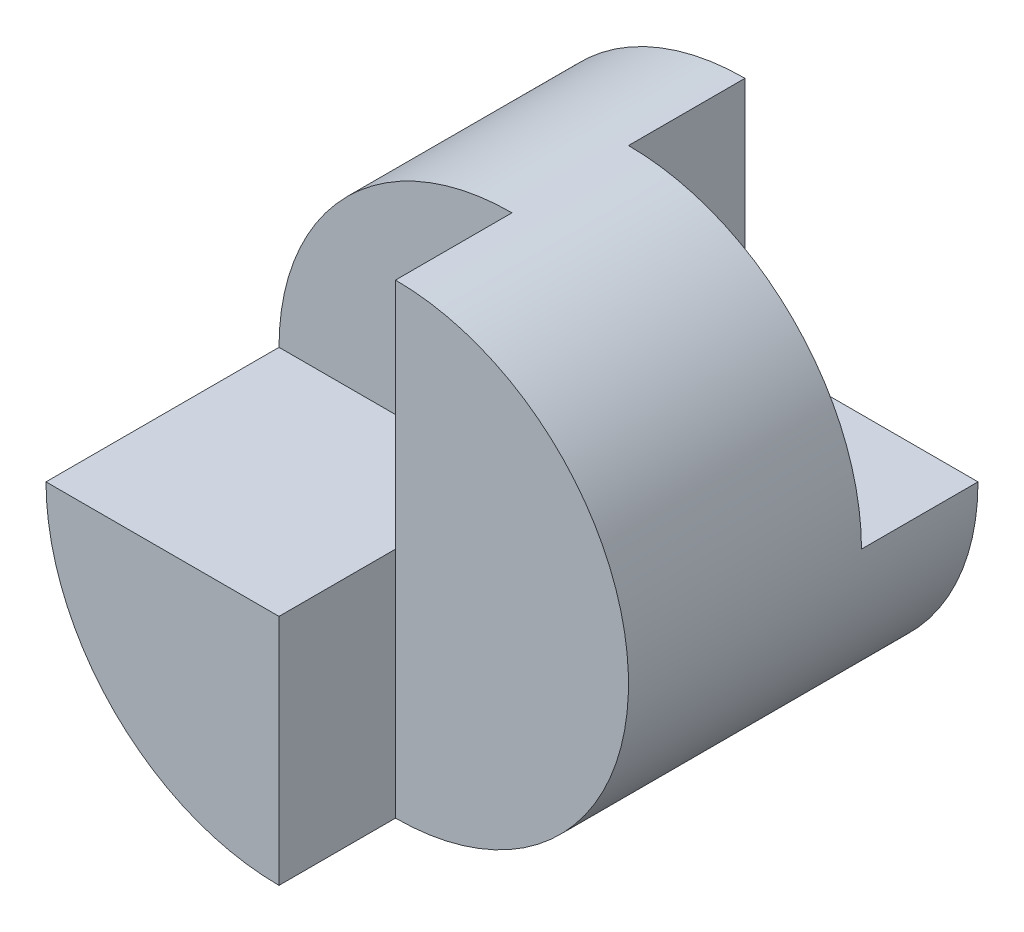
from build123d import *

# Parameters (mm, degrees)
SKETCH1_W           = 40
SKETCH1_H           = 40
BOSS_EXTRUDE1_DEPTH = 40
CUT_EXTRUDE1_DEPTH  = 40
SKETCH3_W           = 20
SKETCH3_H           = 10
CUT_EXTRUDE2_DEPTH  = 40
CUT_EXTRUDE3_DEPTH  = 20
CUT_EXTRUDE4_DEPTH  = 10


with BuildPart() as part:
    # Sketch1 → Boss-Extrude1 (new body)
    with BuildSketch(Plane.XY):
        with Locations((20, 20)):
            Rectangle(SKETCH1_W, SKETCH1_H)
    extrude(amount=BOSS_EXTRUDE1_DEPTH)

    # Sketch2 → Cut-Extrude1 (cut)
    with BuildSketch(Plane.XY.offset(40)):
        with BuildLine():
            Line((20, 40), (0, 40))
            Line((0, 40), (0, 20))
            ThreePointArc((0, 20), (5.857864376, 34.142135624), (20, 40))
        make_face()
        with BuildLine():
            ThreePointArc((20, 0), (5.857864376, 5.857864376), (0, 20))
            Line((0, 20), (0, 0))
            Line((0, 0), (20, 0))
        make_face()
        with BuildLine():
            Line((40, 0), (40, 20))
            ThreePointArc((40, 20), (34.142135624, 5.857864376), (20, 0))
            Line((20, 0), (40, 0))
        make_face()
        with BuildLine():
            Line((40, 40), (20, 40))
            ThreePointArc((20, 40), (34.142135624, 34.142135624), (40, 20))
            Line((40, 20), (40, 40))
        make_face()
    extrude(amount=-CUT_EXTRUDE1_DEPTH, mode=Mode.SUBTRACT)

    # Sketch3 → Cut-Extrude2 (cut)
    with BuildSketch(Plane(origin=(0, 0, 0), x_dir=(1, 0, 0), z_dir=(0, 1, 0))):
        with Locations((30, -35)):
            Rectangle(SKETCH3_W, SKETCH3_H)
    extrude(amount=CUT_EXTRUDE2_DEPTH, mode=Mode.SUBTRACT)

    # Sketch4 → Cut-Extrude3 (cut)
    with BuildSketch(Plane.XY.offset(40)):
        with BuildLine():
            Line((0, 20), (20, 20))
            Line((20, 20), (20, 40))
            ThreePointArc((20, 40), (5.857864376, 34.142135624), (0, 20))
        make_face()
    extrude(amount=-CUT_EXTRUDE3_DEPTH, mode=Mode.SUBTRACT)

    # Sketch5 → Cut-Extrude4 (cut)
    with BuildSketch(Plane(origin=(0, 0, 0), x_dir=(-1, 0, 0), z_dir=(0, 0, -1))):
        with BuildLine():
            Line((-40, 20), (-20, 20))
            Line((-20, 20), (-20, 40))
            ThreePointArc((-20, 40), (-34.142135624, 34.142135624), (-40, 20))
        make_face()
    extrude(amount=-CUT_EXTRUDE4_DEPTH, mode=Mode.SUBTRACT)


solid = part.part
